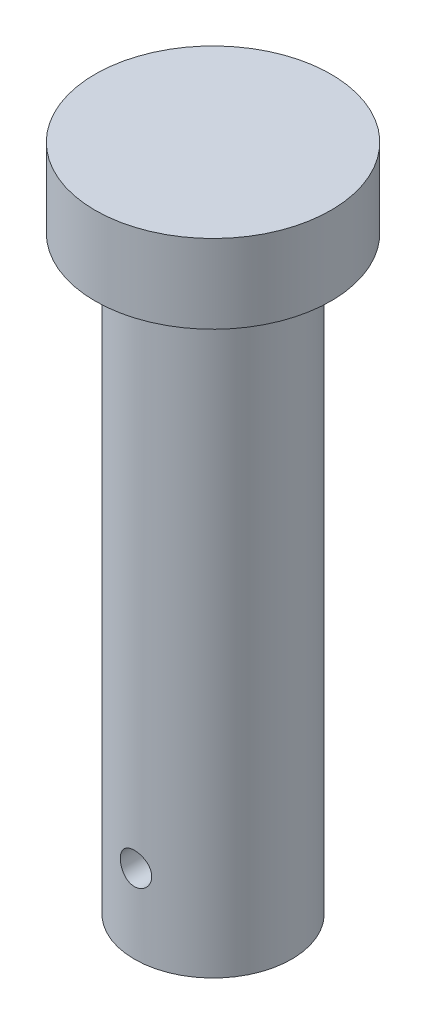
from build123d import *

# Parameters (mm, degrees)
SKETCH1_R                    = 10
BOSS_EXTRUDE1_DEPTH          = 75
SKETCH2_R                    = 15
BOSS_EXTRUDE2_DEPTH          = 10
SKETCH3_R                    = 2
CUT_EXTRUDE1_DEPTH           = 30
CUT_EXTRUDE1_TAPER           = 1
CUT_EXTRUDE1_OTHER_WAY_DEPTH = 30


with BuildPart() as part:
    # Sketch1 → Boss-Extrude1 (new body)
    with BuildSketch(Plane(origin=(0, 0, 0), x_dir=(1, 0, 0), z_dir=(0, 1, 0))):
        Circle(SKETCH1_R)
    extrude(amount=BOSS_EXTRUDE1_DEPTH)

    # Sketch2 → Boss-Extrude2 (add)
    with BuildSketch(Plane(origin=(0, 75, 0), x_dir=(1, 0, 0), z_dir=(0, 1, 0))):
        Circle(SKETCH2_R)
    extrude(amount=BOSS_EXTRUDE2_DEPTH)

    # Sketch3 → Cut-Extrude1 (cut)
    with BuildSketch(Plane.XY):
        with Locations((0, 10)):
            Circle(SKETCH3_R)
    extrude(amount=-CUT_EXTRUDE1_DEPTH, taper=CUT_EXTRUDE1_TAPER, mode=Mode.SUBTRACT)

    # Sketch3 → Cut-Extrude1 other way (cut)
    with BuildSketch(Plane.XY):
        with Locations((0, 10)):
            Circle(SKETCH3_R)
    extrude(amount=CUT_EXTRUDE1_OTHER_WAY_DEPTH, mode=Mode.SUBTRACT)


solid = part.part
